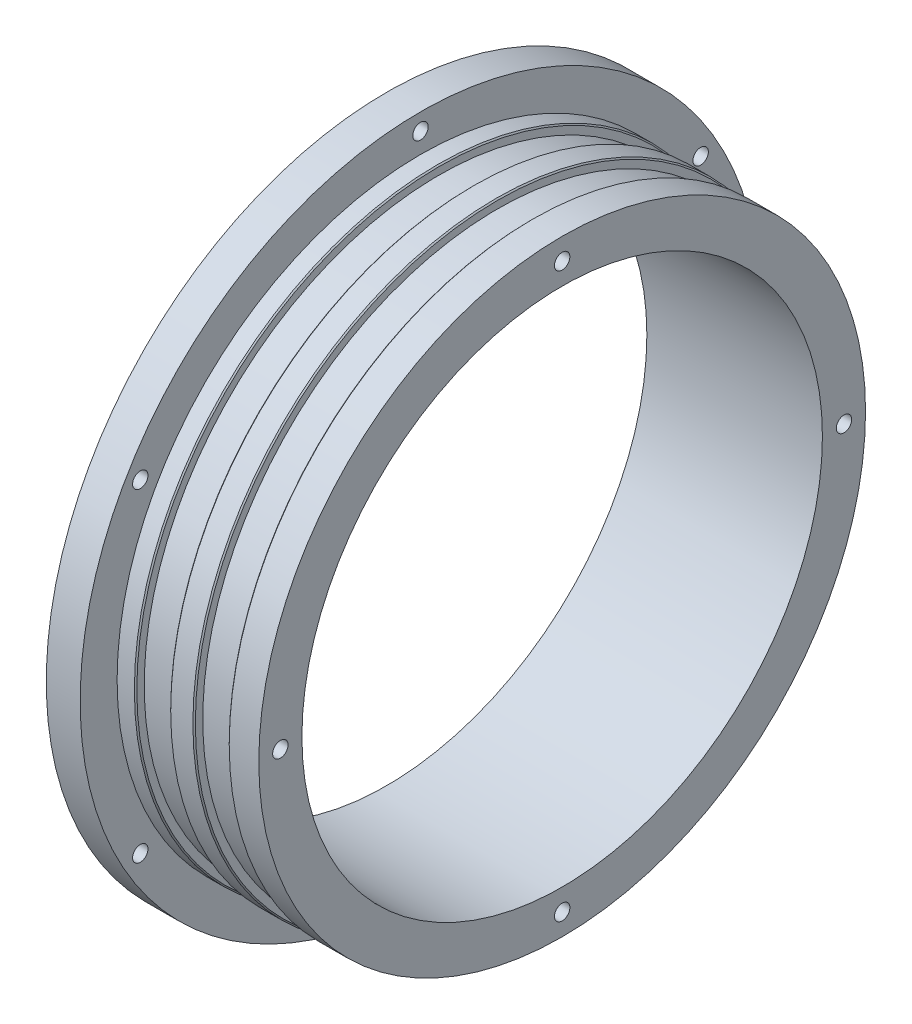
from build123d import *

# Parameters (mm, degrees)
CHAMFER_1_SIZE = 0.2
M3X0_5_2_D     = 2.5
M3X0_5_2_DEPTH = 4
M3X0_5_2_TIP   = 0.751075774
M3X0_5_3_D     = 2.5
M3X0_5_3_DEPTH = 4
M3X0_5_3_TIP   = 0.751075774
M3X0_5_4_D     = 2.5


with BuildPart() as part:
    # 草图2 → 旋转1 (revolve)
    with BuildSketch(Plane(origin=(0, 0, 0), x_dir=(1, 0, 0), z_dir=(0, 1, 0))):
        Polygon((-77.680952315, 55.25), (-72.180952315, 55.25), (-72.180952315, 49.25), (-69.180952315, 49.25), (-69.180952315, 47.85), (-63.680952315, 47.85), (-63.680952315, 49.25), (-59.680952315, 49.25), (-59.680952315, 47.85), (-54.180952315, 47.85), (-54.180952315, 49.25), (-49.180952315, 49.25), (-49.180952315, 42.25), (-77.680952315, 42.25), (-77.680952315, 46.2), (-76.780952315, 46.2), (-76.780952315, 49.8), (-77.680952315, 49.8), align=None)
    revolve(axis=Axis((0, 0, 0), (-1, 0, 0)))

    # 倒角1
    chamfer_1_edges = [part.edges().sort_by_distance(p)[0] for p in [
        (-77.680952315, 0, 49.8),
        (-77.680952315, 0, 46.2),
        (-54.180952315, 0, 49.25),
        (-59.680952315, 0, 49.25),
        (-63.680952315, 0, 49.25),
        (-69.180952315, 0, 49.25),
    ]]
    chamfer(chamfer_1_edges, length=CHAMFER_1_SIZE)

    # M3x0.5 螺纹孔2
    with Locations(Plane(origin=(-49.180952315, 45.75, 0), x_dir=(0, 0, 1), z_dir=(1, 0, 0))):
        with Locations((0, 0)):
            Hole(M3X0_5_2_D / 2, depth=M3X0_5_2_DEPTH)
            with Locations((0, 0, -(M3X0_5_2_DEPTH + M3X0_5_2_TIP / 2))):  # 118° drill point
                Cone(0, M3X0_5_2_D / 2, M3X0_5_2_TIP, mode=Mode.SUBTRACT)

    # M3x0.5 螺纹孔3
    with Locations(Plane(origin=(-49.180952315, 0, -45.75), x_dir=(0, 0, 1), z_dir=(1, 0, 0))):
        with Locations((0, 0), (91.5, 0), (45.75, 45.75)):
            Hole(M3X0_5_3_D / 2, depth=M3X0_5_3_DEPTH)
            with Locations((0, 0, -(M3X0_5_3_DEPTH + M3X0_5_3_TIP / 2))):  # 118° drill point
                Cone(0, M3X0_5_3_D / 2, M3X0_5_3_TIP, mode=Mode.SUBTRACT)

    # M3x0.5 螺纹孔4 (through all)
    with Locations(Plane(origin=(-77.680952315, 52.525, 0), x_dir=(0, 0, -1), z_dir=(-1, 0, 0))):
        with Locations((0, 0), (-45.487984334, 26.2625), (-45.487984334, 78.7875), (0, 105.05), (45.487984334, 78.7875), (45.487984334, 26.2625)):
            Hole(M3X0_5_4_D / 2)


solid = part.part
